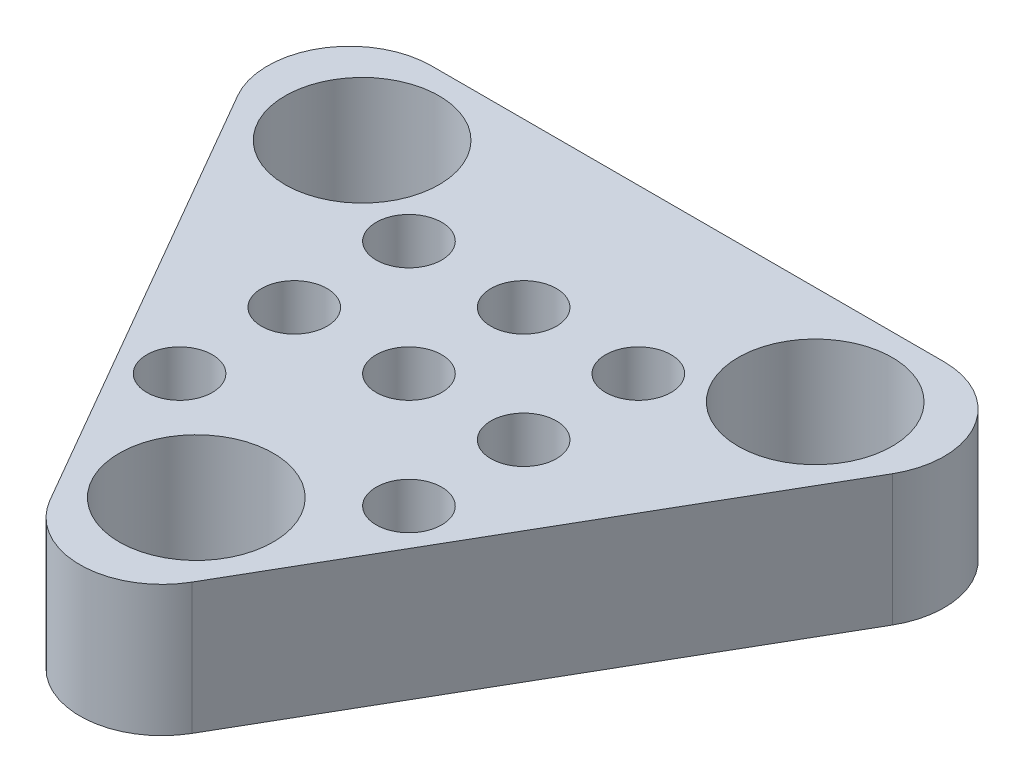
from build123d import *

# Parameters (mm, degrees)
SKETCH1_R      = 2.35
SKETCH1_R_2    = 1
EXTRUDE1_DEPTH = 4


with BuildPart() as part:
    # Sketch1 → Extrude1 (new body)
    with BuildSketch(Plane(origin=(0, 0, 0), x_dir=(1, 0, 0), z_dir=(0, 1, 0))):
        with BuildLine():
            Line((-5.186041147, 3.316192399), (2.637731834, -10.234979911))
            ThreePointArc((2.637731834, -10.234979911), (4.802795343, -11.484979911), (6.967858853, -10.234979911))
            Line((6.967858853, -10.234979911), (14.791631834, 3.316192399))
            ThreePointArc((14.791631834, 3.316192399), (14.791631834, 5.816192399), (12.626568324, 7.066192399))
            Line((12.626568324, 7.066192399), (-3.020977638, 7.066192399))
            ThreePointArc((-3.020977638, 7.066192399), (-5.186041147, 5.816192399), (-5.186041147, 3.316192399))
        make_face()
        with Locations((-2.110635714, 4.040606244)):
            Circle(SKETCH1_R, mode=Mode.SUBTRACT)
        with Locations((4.802795343, -7.933807601)):
            Circle(SKETCH1_R, mode=Mode.SUBTRACT)
        with Locations((11.7162264, 4.040606244)):
            Circle(SKETCH1_R, mode=Mode.SUBTRACT)
        with Locations((1.270334632, 2.088602105)):
            Circle(SKETCH1_R_2, mode=Mode.SUBTRACT)
        with Locations((4.770334632, 2.088602105)):
            Circle(SKETCH1_R_2, mode=Mode.SUBTRACT)
        with Locations((8.270334632, 2.088602105)):
            Circle(SKETCH1_R_2, mode=Mode.SUBTRACT)
        with Locations((1.270334632, -1.411397895)):
            Circle(SKETCH1_R_2, mode=Mode.SUBTRACT)
        with Locations((4.770334632, -1.411397895)):
            Circle(SKETCH1_R_2, mode=Mode.SUBTRACT)
        with Locations((8.270334632, -1.411397895)):
            Circle(SKETCH1_R_2, mode=Mode.SUBTRACT)
        with Locations((1.270334632, -4.911397895)):
            Circle(SKETCH1_R_2, mode=Mode.SUBTRACT)
        with Locations((8.270334632, -4.911397895)):
            Circle(SKETCH1_R_2, mode=Mode.SUBTRACT)
    extrude(amount=EXTRUDE1_DEPTH)


solid = part.part
